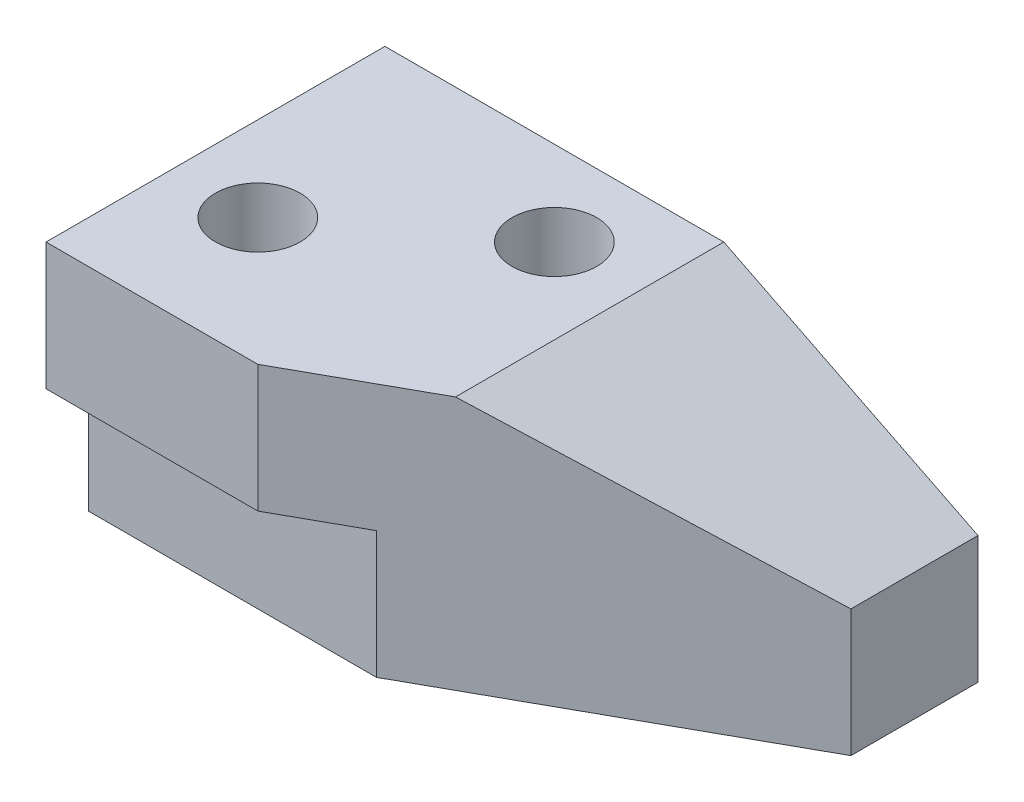
from build123d import *

# Parameters (mm, degrees)
SKETCH1_W           = 70
SKETCH1_H           = 40
BOSS_EXTRUDE1_DEPTH = 30
CUT_EXTRUDE1_DEPTH  = 41
CUT_EXTRUDE2_DEPTH  = 31
SKETCH5_W           = 5
SKETCH5_H           = 15
CUT_EXTRUDE3_DEPTH  = 71
SKETCH6_R           = 5
CUT_EXTRUDE4_DEPTH  = 31
SKETCH7_R           = 5
CUT_EXTRUDE5_DEPTH  = 31


with BuildPart() as part:
    # Sketch1 → Boss-Extrude1 (new body)
    with BuildSketch(Plane(origin=(0, 0, 0), x_dir=(1, 0, 0), z_dir=(0, 1, 0))):
        with Locations((35, 20)):
            Rectangle(SKETCH1_W, SKETCH1_H)
    extrude(amount=BOSS_EXTRUDE1_DEPTH)

    # Sketch2 → Cut-Extrude1 (cut, through all)
    with BuildSketch(Plane.XY):
        Polygon((70, 30), (40, 30), (70, 15), align=None)
    extrude(amount=-CUT_EXTRUDE1_DEPTH, mode=Mode.SUBTRACT)

    # Sketch4 → Cut-Extrude2 (cut, through all)
    with BuildSketch(Plane(origin=(0, 0, 0), x_dir=(-1, 0, 0), z_dir=(0, -1, 0))):
        Polygon((-25, 0), (-70, 25), (-70, 0), align=None)
    extrude(amount=-CUT_EXTRUDE2_DEPTH, mode=Mode.SUBTRACT)

    # Sketch5 → Cut-Extrude3 (cut, through all)
    with BuildSketch(Plane.ZY):
        with Locations((-2.5, 7.5)):
            Rectangle(SKETCH5_W, SKETCH5_H)
    extrude(amount=-CUT_EXTRUDE3_DEPTH, mode=Mode.SUBTRACT)

    # Sketch6 → Cut-Extrude4 (cut, through all)
    with BuildSketch(Plane(origin=(0, 30, 0), x_dir=(1, 0, 0), z_dir=(0, 1, 0))):
        with Locations((10, 15)):
            Circle(SKETCH6_R)
    extrude(amount=-CUT_EXTRUDE4_DEPTH, mode=Mode.SUBTRACT)

    # Sketch7 → Cut-Extrude5 (cut, through all)
    with BuildSketch(Plane(origin=(0, 30, 0), x_dir=(1, 0, 0), z_dir=(0, 1, 0))):
        with Locations((30, 30)):
            Circle(SKETCH7_R)
    extrude(amount=-CUT_EXTRUDE5_DEPTH, mode=Mode.SUBTRACT)


solid = part.part
